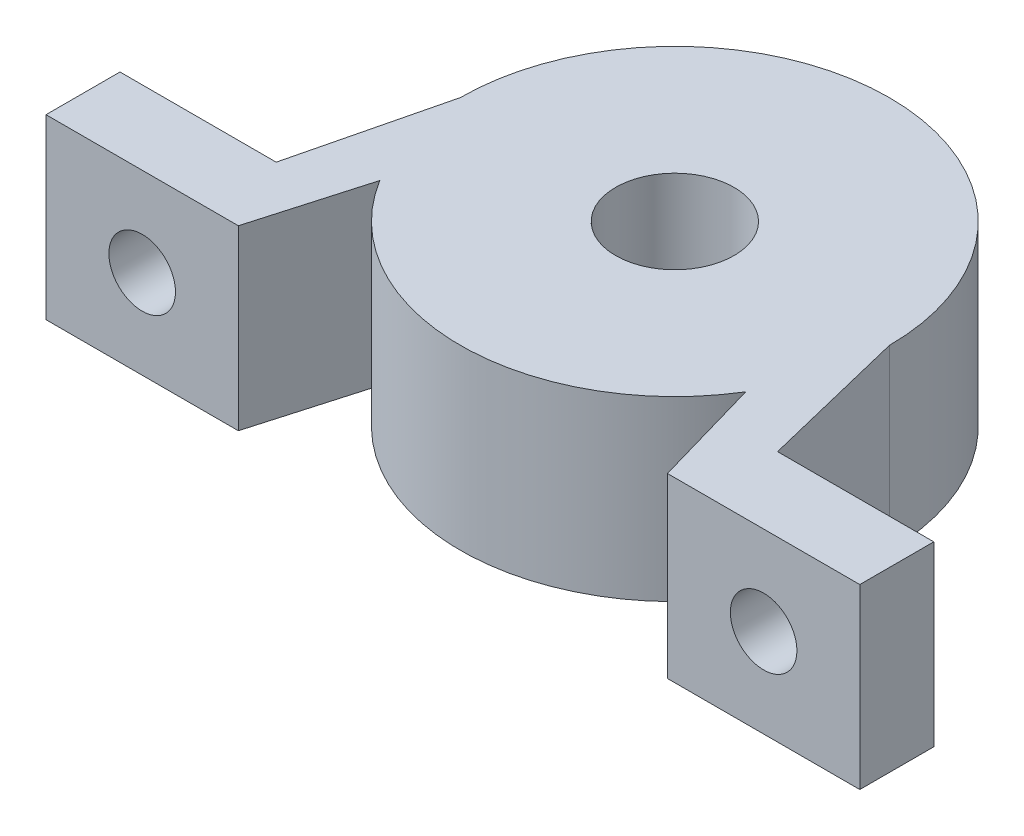
from build123d import *

# Parameters (mm, degrees)
SKETCH1_R           = 4
BOSS_EXTRUDE1_DEPTH = 12
SKETCH2_R           = 2.25
CUT_EXTRUDE1_DEPTH  = 12


with BuildPart() as part:
    # Sketch1 → Boss-Extrude1 (new body)
    with BuildSketch(Plane(origin=(0, 0, 0), x_dir=(1, 0, 0), z_dir=(0, 1, 0))):
        with BuildLine():
            Line((-27.5, -10), (-27.5, -15))
            Line((-27.5, -15), (-14.5, -15))
            Line((-14.5, -15), (-12.366440747, -7.571072794))
            ThreePointArc((-12.366440747, -7.571072794), (0, -14.5), (12.366440747, -7.571072794))
            Line((12.366440747, -7.571072794), (14.5, -15))
            Line((14.5, -15), (27.5, -15))
            Line((27.5, -15), (27.5, -10))
            Line((27.5, -10), (16.942866484, -10))
            Line((16.942866484, -10), (14.5, 0))
            ThreePointArc((14.5, 0), (0, 14.5), (-14.5, 0))
            Line((-14.5, 0), (-16.942866484, -10))
            Line((-16.942866484, -10), (-27.5, -10))
        make_face()
        Circle(SKETCH1_R, mode=Mode.SUBTRACT)
    extrude(amount=BOSS_EXTRUDE1_DEPTH)

    # Sketch2 → Cut-Extrude1 (cut)
    with BuildSketch(Plane.XY.offset(15)):
        with Locations((-21, 6)):
            Circle(SKETCH2_R)
        with Locations((21, 6)):
            Circle(SKETCH2_R)
    extrude(amount=-CUT_EXTRUDE1_DEPTH, mode=Mode.SUBTRACT)


solid = part.part
